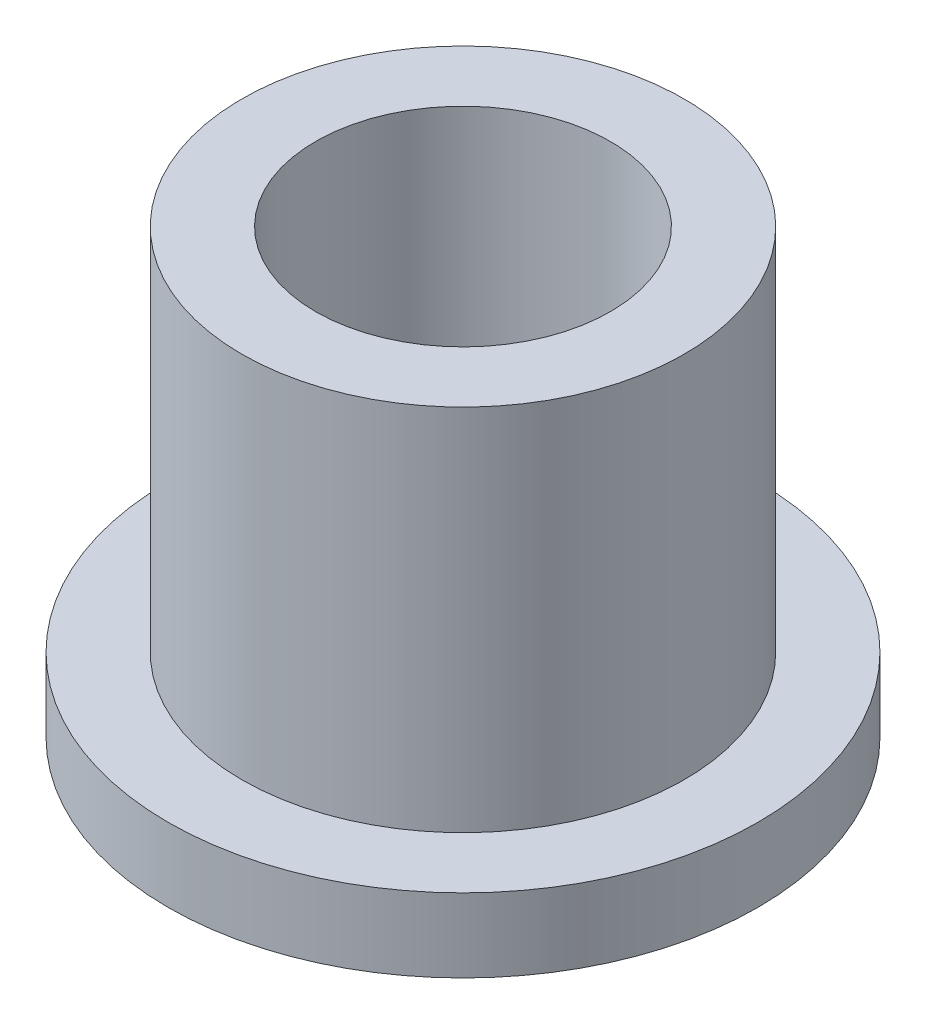
from build123d import *

# Parameters (mm, degrees)
SKETCH2_R           = 4.7625
SKETCH2_R_2         = 3.175
BOSS_EXTRUDE1_DEPTH = 9.525
SKETCH3_R           = 6.35
SKETCH3_R_2         = 4.7625
BOSS_EXTRUDE2_DEPTH = 1.5875


with BuildPart() as part:
    # Sketch2 → Boss-Extrude1 (new body)
    with BuildSketch(Plane(origin=(0, 0, 0), x_dir=(1, 0, 0), z_dir=(0, 1, 0))):
        Circle(SKETCH2_R)
        Circle(SKETCH2_R_2, mode=Mode.SUBTRACT)
    extrude(amount=BOSS_EXTRUDE1_DEPTH)

    # Sketch3 → Boss-Extrude2 (add)
    with BuildSketch(Plane(origin=(0, 0, 0), x_dir=(1, 0, 0), z_dir=(0, 1, 0))):
        Circle(SKETCH3_R)
        Circle(SKETCH3_R_2, mode=Mode.SUBTRACT)
    extrude(amount=BOSS_EXTRUDE2_DEPTH)


solid = part.part
